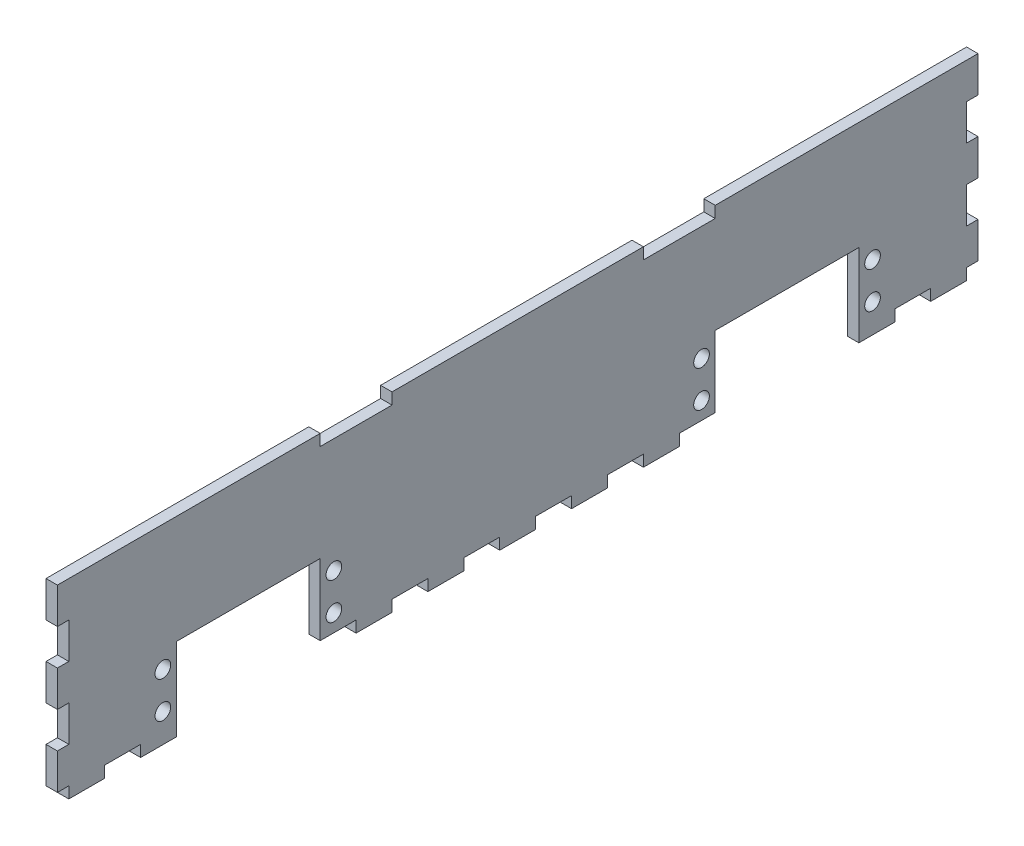
from build123d import *

# Parameters (mm, degrees)
ESQUISSE1_W                = 250
ESQUISSE1_H                = 50
BOSS_EXTRU_1_DEPTH         = 3.175
ESQUISSE2_W                = 10
ESQUISSE2_H                = 3.175
BOSS_EXTRU_2_DEPTH         = 3.175
R_P_TITION_LIN_AIRE1_COUNT = 13
R_P_TITION_LIN_AIRE1_PITCH = 20
ESQUISSE4_W                = 40
ESQUISSE4_H                = 23
ESQUISSE4_W_2              = 20
ESQUISSE4_H_2              = 3.175
ENL_V_MAT_EXTRU_1_DEPTH    = 3.175
ESQUISSE5_W                = 3.175
ESQUISSE5_H                = 10
BOSS_EXTRU_3_DEPTH         = 3.175
R_P_TITION_LIN_AIRE2_COUNT = 3
R_P_TITION_LIN_AIRE2_PITCH = 20
ESQUISSE6_R                = 2.18
ENL_V_MAT_EXTRU_2_DEPTH    = 10


with BuildPart() as part:
    # Esquisse1 → Boss.-Extru.1 (new body)
    with BuildSketch(Plane(origin=(0, 0, 0), x_dir=(0, 0, -1), z_dir=(1, 0, 0))):
        with Locations((125, 25)):
            Rectangle(ESQUISSE1_W, ESQUISSE1_H)
    extrude(amount=BOSS_EXTRU_1_DEPTH)

    # Esquisse2 → Boss.-Extru.2 (add)
    with BuildSketch(Plane(origin=(3.175, 0, 0), x_dir=(0, 0, -1), z_dir=(1, 0, 0))):
        with Locations((5, -1.5875)):
            Rectangle(ESQUISSE2_W, ESQUISSE2_H)
    boss_extru_2 = extrude(amount=-BOSS_EXTRU_2_DEPTH)

    # Répétition linéaire1: Boss.-Extru.2 ×13
    with Locations(*[(0, 0, -i * R_P_TITION_LIN_AIRE1_PITCH) for i in range(1, R_P_TITION_LIN_AIRE1_COUNT)]):
        add(boss_extru_2)

    # Esquisse4 → Enlèv. mat.-Extru.1 (cut)
    with BuildSketch(Plane(origin=(3.175, 0, 0), x_dir=(0, 0, -1), z_dir=(1, 0, 0))):
        with Locations((50, 8.325)):
            Rectangle(ESQUISSE4_W, ESQUISSE4_H)
        with Locations((200, 8.325)):
            Rectangle(ESQUISSE4_W, ESQUISSE4_H)
        with Locations((80, 48.4125)):
            Rectangle(ESQUISSE4_W_2, ESQUISSE4_H_2)
        with Locations((170, 48.4125)):
            Rectangle(ESQUISSE4_W_2, ESQUISSE4_H_2)
    extrude(amount=-ENL_V_MAT_EXTRU_1_DEPTH, mode=Mode.SUBTRACT)

    # Esquisse5 → Boss.-Extru.3 (add)
    with BuildSketch(Plane(origin=(3.175, 0, 0), x_dir=(0, 0, -1), z_dir=(1, 0, 0))):
        with Locations((-1.5875, 45)):
            Rectangle(ESQUISSE5_W, ESQUISSE5_H)
        with Locations((251.5875, 45)):
            Rectangle(ESQUISSE5_W, ESQUISSE5_H)
    boss_extru_3 = extrude(amount=-BOSS_EXTRU_3_DEPTH)

    # Répétition linéaire2: Boss.-Extru.3 ×3
    with Locations(*[(0, -i * R_P_TITION_LIN_AIRE2_PITCH, 0) for i in range(1, R_P_TITION_LIN_AIRE2_COUNT)]):
        add(boss_extru_3)

    # Esquisse6 → Enlèv. mat.-Extru.2 (cut)
    with BuildSketch(Plane(origin=(3.175, 0, 0), x_dir=(0, 0, -1), z_dir=(1, 0, 0))):
        with Locations((73.81, 14.99)):
            Circle(ESQUISSE6_R)
        with Locations((73.81, 4.83)):
            Circle(ESQUISSE6_R)
        with Locations((26.19, 14.99)):
            Circle(ESQUISSE6_R)
        with Locations((26.19, 4.83)):
            Circle(ESQUISSE6_R)
        with Locations((176.19, 14.99)):
            Circle(ESQUISSE6_R)
        with Locations((176.19, 4.83)):
            Circle(ESQUISSE6_R)
        with Locations((223.81, 4.83)):
            Circle(ESQUISSE6_R)
        with Locations((223.81, 14.99)):
            Circle(ESQUISSE6_R)
    extrude(amount=-ENL_V_MAT_EXTRU_2_DEPTH, mode=Mode.SUBTRACT)


solid = part.part
